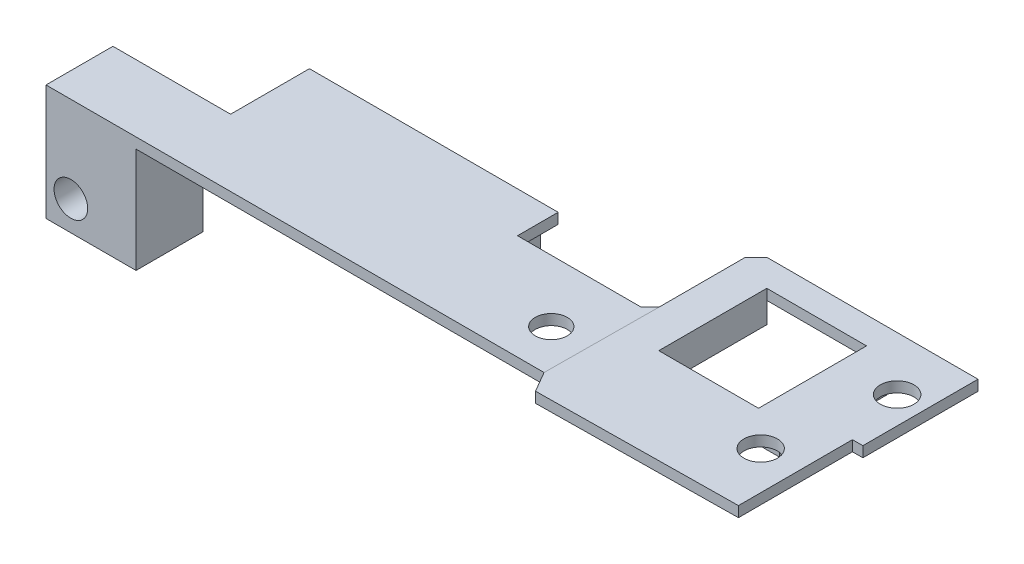
from build123d import *

# Parameters (mm, degrees)
SKETCH_1_R          = 1.524071043
SKETCH_1_R_2        = 1.6
EXTRUDE_1_DEPTH     = 1
SKETCH_2_W          = 21.996438878
SKETCH_2_H          = 1.4
EXTRUDE_2_DEPTH     = 9
SKETCH_3_W          = 9.861847607
SKETCH_3_H          = 7.366382786
EXTRUDE_3_DEPTH     = 10
SKETCH_5_R          = 1.6
CUT_EXTRUDE_1_DEPTH = 7.366383
CUT_EXTRUDE_2_DEPTH = 12
SKETCH_7_R          = 1.592573362
SKETCH_7_R_2        = 1.6
SKETCH_7_W          = 9.485642318
SKETCH_7_H          = 10.27215013
EXTRUDE_4_DEPTH     = 1
SKETCH_8_W          = 1.691344217
SKETCH_8_H          = 10.298863766
SKETCH_8_W_2        = 2.005424039
EXTRUDE_5_DEPTH     = 2
SKETCH_9_W          = 1.3
SKETCH_9_H          = 7.366382786
CUT_EXTRUDE_3_DEPTH = 11
SKETCH_10_W         = 11.187081985
SKETCH_10_H         = 1
CUT_EXTRUDE_4_DEPTH = 11


with BuildPart() as part:
    # 草图1 → 凸台-拉伸1 (new body)
    with BuildSketch(Plane(origin=(0, 0, 0), x_dir=(1, 0, 0), z_dir=(0, 1, 0))):
        Polygon((-59.259088641, 5), (-10.592885375, 5), (-7.033226841, 1.452276921), (10.592885375, 1.452276921), (10.592885375, -5), (10.592885375, -12.524779967), (-8.311746214, -12.524779967), (-10.311746214, -10.524779967), (-10.311746214, -6.052343932), (-11.311746214, -5.052343932), (-11.364090146, -5), (-23.120004307, -5), (-23.120004307, -8.866382786), (-46.772006656, -8.866382786), (-46.772006656, -2.366382786), (-59.259088641, -2.366382786), (-59.259088641, 0), align=None)
        with Locations((-14.030480272, 0.876017114)):
            Circle(SKETCH_1_R, mode=Mode.SUBTRACT)
        with Locations((5.968790226, -10.352689008)):
            Circle(SKETCH_1_R_2, mode=Mode.SUBTRACT)
    extrude_1 = extrude(amount=EXTRUDE_1_DEPTH)

    # 草图2 → 凸台-拉伸2 (add)
    with BuildSketch(Plane.XZ):
        with Locations((-35.773787217, 8.166382786)):
            Rectangle(SKETCH_2_W, SKETCH_2_H)
    extrude_2 = extrude(amount=EXTRUDE_2_DEPTH)

    # 草图3 → 凸台-拉伸3 (add)
    with BuildSketch(Plane.XZ):
        with Locations((-54.328164838, -1.316808607)):
            Rectangle(SKETCH_3_W, SKETCH_3_H)
    extrude_3 = extrude(amount=EXTRUDE_3_DEPTH)

    # 草图5 → 切除-拉伸1 (cut)
    with BuildSketch(Plane.XY.offset(2.366382786)):
        with Locations((-55.594883285, -7.2)):
            Circle(SKETCH_5_R)
    cut_extrude_1 = extrude(amount=-CUT_EXTRUDE_1_DEPTH, mode=Mode.SUBTRACT)

    # 镜向3: 凸台-拉伸1, 凸台-拉伸2, 凸台-拉伸3, 切除-拉伸1 across plane
    add(extrude_1.mirror(Plane(origin=(-59.259088641, 1, -5), x_dir=(1, 0, 0), z_dir=(0, 0, 1))))
    add(extrude_2.mirror(Plane(origin=(-59.259088641, 1, -5), x_dir=(1, 0, 0), z_dir=(0, 0, 1))))
    add(extrude_3.mirror(Plane(origin=(-59.259088641, 1, -5), x_dir=(1, 0, 0), z_dir=(0, 0, 1))))
    add(cut_extrude_1.mirror(Plane(origin=(-59.259088641, 1, -5), x_dir=(1, 0, 0), z_dir=(0, 0, 1))), mode=Mode.SUBTRACT)

    # 草图6 → 切除-拉伸2 (cut, through all)
    with BuildSketch(Plane(origin=(0, 1, 0), x_dir=(1, 0, 0), z_dir=(0, 1, 0))):
        Polygon((-59.259088641, 5), (-10.592885375, 5), (-10.459693835, 22.524779967), (10.592885375, 22.524779967), (10.592885375, 5), (10.592885375, -12.524779967), (-59.259088641, -12.524779967), align=None)
    extrude(amount=-CUT_EXTRUDE_2_DEPTH, mode=Mode.SUBTRACT)

    # 草图9 → 切除-拉伸3 (cut)
    with BuildSketch(Plane(origin=(0, 1, 0), x_dir=(1, 0, 0), z_dir=(0, 1, 0))):
        with Locations((-58.609088641, 8.683191393)):
            Rectangle(SKETCH_9_W, SKETCH_9_H)
    extrude(amount=-CUT_EXTRUDE_3_DEPTH, mode=Mode.SUBTRACT)

    # 草图10 → 切除-拉伸4 (cut)
    with BuildSketch(Plane(origin=(0, 1, 0), x_dir=(1, 0, 0), z_dir=(0, 1, 0))):
        with Locations((-52.365547648, 11.866382786)):
            Rectangle(SKETCH_10_W, SKETCH_10_H)
    extrude(amount=-CUT_EXTRUDE_4_DEPTH, mode=Mode.SUBTRACT)


with BuildPart() as body_2:
    # 草图7 → 凸台-拉伸4 (new body)
    with BuildSketch(Plane(origin=(0, 1, 0), x_dir=(1, 0, 0), z_dir=(0, 1, 0))):
        Polygon((-10.510395305, 15.853694841), (-10.510395305, 24.029624988), (-9.458493443, 25.081526849), (6.768801236, 25.081526849), (10.592885375, 25.081526849), (10.592885375, 14.132157603), (9.601232072, 14.132157603), (9.610867698, 3.283603617), (-9.458493443, 3.052343932), (-10.592885375, 5), align=None)
        with Locations((5.968790226, 9.039428566)):
            Circle(SKETCH_7_R, mode=Mode.SUBTRACT)
        with Locations((8.010144522, 19.973832655)):
            Circle(SKETCH_7_R_2, mode=Mode.SUBTRACT)
        with Locations((-2.192808553, 17.388704902)):
            Rectangle(SKETCH_7_W, SKETCH_7_H, mode=Mode.SUBTRACT)
    extrude(amount=-EXTRUDE_4_DEPTH)

    # 草图8 → 凸台-拉伸5 (add)
    with BuildSketch(Plane.XZ):
        with Locations((-7.781301821, -17.375348084)):
            Rectangle(SKETCH_8_W, SKETCH_8_H)
        with Locations((3.552724626, -17.375348084)):
            Rectangle(SKETCH_8_W_2, SKETCH_8_H)
    extrude(amount=EXTRUDE_5_DEPTH)


solid = Compound([part.part, body_2.part])
